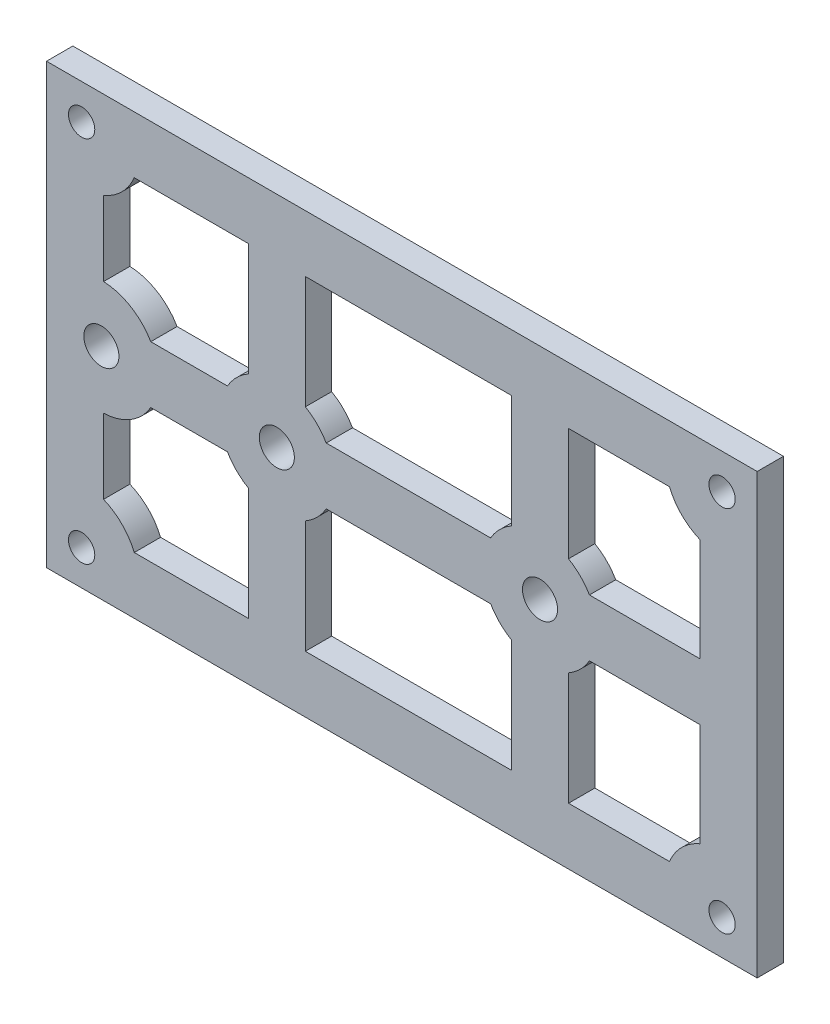
from build123d import *

# Parameters (mm, degrees)
SKETCH1_W           = 81
SKETCH1_H           = 50
SKETCH1_R           = 2
SKETCH1_R_2         = 1.5
BOSS_EXTRUDE1_DEPTH = 3
CUT_EXTRUDE1_DEPTH  = 4


with BuildPart() as part:
    # Sketch1 → Boss-Extrude1 (new body)
    with BuildSketch(Plane.XY):
        Rectangle(SKETCH1_W, SKETCH1_H)
        with Locations((-34.25, 0)):
            Circle(SKETCH1_R, mode=Mode.SUBTRACT)
        with Locations((-14.25, 0)):
            Circle(SKETCH1_R, mode=Mode.SUBTRACT)
        with Locations((15.75, 0)):
            Circle(SKETCH1_R, mode=Mode.SUBTRACT)
        with Locations((-36.5, 21)):
            Circle(SKETCH1_R_2, mode=Mode.SUBTRACT)
        with Locations((36.5, 21)):
            Circle(SKETCH1_R_2, mode=Mode.SUBTRACT)
        with Locations((36.5, -21)):
            Circle(SKETCH1_R_2, mode=Mode.SUBTRACT)
        with Locations((-36.5, -21)):
            Circle(SKETCH1_R_2, mode=Mode.SUBTRACT)
    extrude(amount=BOSS_EXTRUDE1_DEPTH)

    # Sketch3 → Cut-Extrude1 (cut, through all)
    with BuildSketch(Plane.XY.offset(3)):
        with BuildLine():
            Line((30.5, 18.5), (19, 18.5))
            Line((19, 18.5), (19, 5.629165125))
            ThreePointArc((19, 5.629165125), (20.346194078, 4.596194078), (21.379165125, 3.25))
            Line((21.379165125, 3.25), (34, 3.25))
            Line((34, 3.25), (34, 15))
            ThreePointArc((34, 15), (31.903805922, 16.403805922), (30.5, 18.5))
        make_face()
        with BuildLine():
            Line((12.5, 5.629165125), (12.5, 18.5))
            Line((12.5, 18.5), (-11, 18.5))
            Line((-11, 18.5), (-11, 5.629165125))
            ThreePointArc((-11, 5.629165125), (-9.653805922, 4.596194078), (-8.620834875, 3.25))
            Line((-8.620834875, 3.25), (10.120834875, 3.25))
            ThreePointArc((10.120834875, 3.25), (11.153805922, 4.596194078), (12.5, 5.629165125))
        make_face()
        with BuildLine():
            Line((-28.620834875, 3.25), (-19.879165125, 3.25))
            ThreePointArc((-19.879165125, 3.25), (-18.846194078, 4.596194078), (-17.5, 5.629165125))
            Line((-17.5, 5.629165125), (-17.5, 18.5))
            Line((-17.5, 18.5), (-30.5, 18.5))
            ThreePointArc((-30.5, 18.5), (-31.903805922, 16.403805922), (-34, 15))
            Line((-34, 15), (-34, 6.495190528))
            ThreePointArc((-34, 6.495190528), (-30.892328034, 5.565612183), (-28.620834875, 3.25))
        make_face()
    cut_extrude1 = extrude(amount=-CUT_EXTRUDE1_DEPTH, mode=Mode.SUBTRACT)

    # Mirror2: Cut-Extrude1 across plane
    add(cut_extrude1.mirror(Plane.ZX), mode=Mode.SUBTRACT)


solid = part.part
